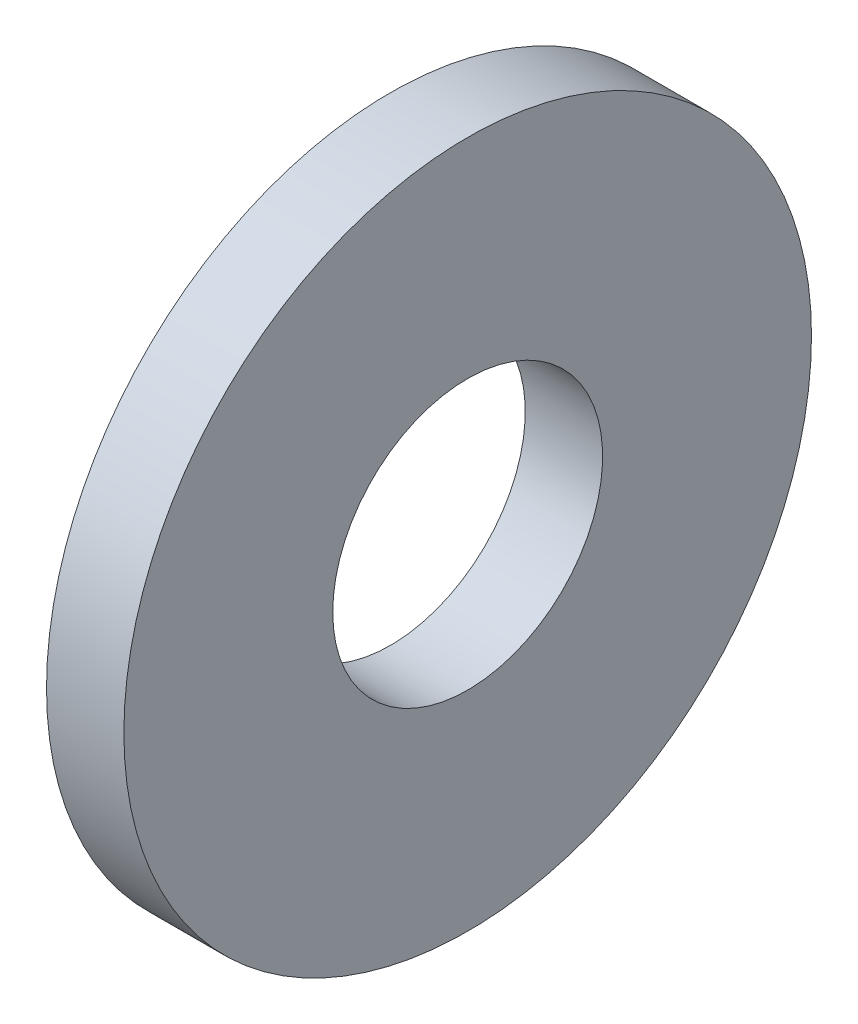
from build123d import *

# Parameters (mm, degrees)
SKETCH1_W = 0.9
SKETCH1_H = 2.43


with BuildPart() as part:
    # Sketch1 → Base-Revolve (revolve)
    with BuildSketch(Plane.XY):
        with Locations((-0.45, 2.785)):
            Rectangle(SKETCH1_W, SKETCH1_H)
    revolve(axis=Axis((-34.925, 0, 0), (1, 0, 0)))


solid = part.part
